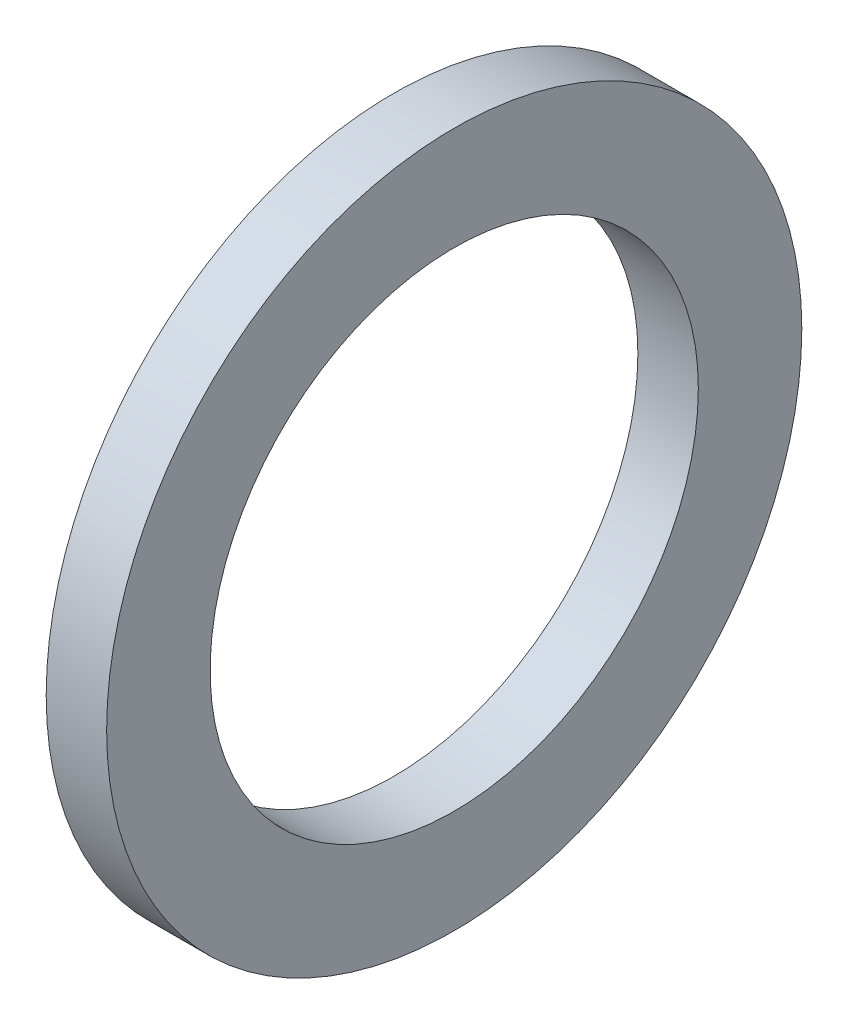
from build123d import *

# Parameters (mm, degrees)
SKETCH1_R           = 11.5
SKETCH1_R_2         = 8.076127585
BOSS_EXTRUDE1_DEPTH = 2


with BuildPart() as part:
    # Sketch1 → Boss-Extrude1 (new body)
    with BuildSketch(Plane(origin=(0, 0, 0), x_dir=(0, 0, -1), z_dir=(1, 0, 0))):
        Circle(SKETCH1_R)
        Circle(SKETCH1_R_2, mode=Mode.SUBTRACT)
    extrude(amount=BOSS_EXTRUDE1_DEPTH)


solid = part.part
